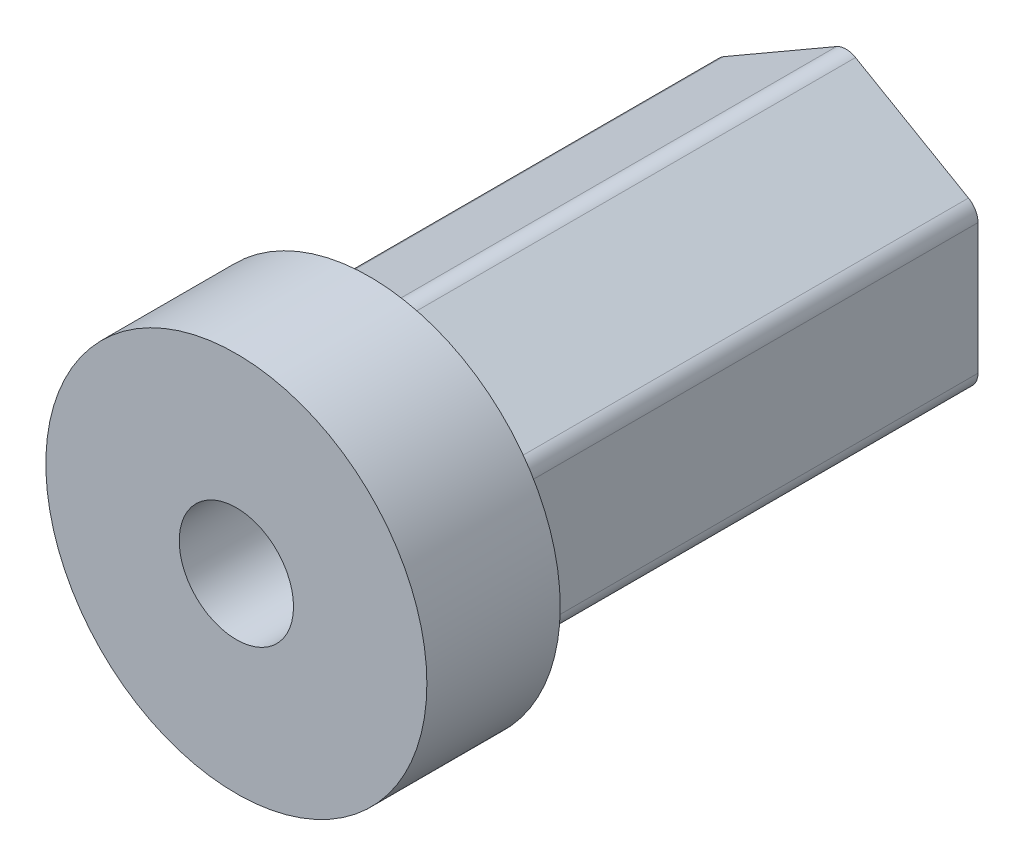
from build123d import *

# Parameters (mm, degrees)
CUT_EXTRUDE1_DEPTH = 25
FILLET1_R          = 1


with BuildPart() as part:
    # Sketch2 → Revolve1 (revolve)
    with BuildSketch(Plane(origin=(0, 0, 0), x_dir=(0, 0, -1), z_dir=(1, 0, 0))):
        Polygon((-7, 3), (25, 3), (25, 8), (0, 8), (0, 10), (-7, 10), align=None)
    revolve(axis=Axis((0, 0, 0), (0, 0, -1)))

    # Sketch3 → Cut-Extrude1 (cut)
    with BuildSketch(Plane(origin=(0, 0, -25), x_dir=(-1, 0, 0), z_dir=(0, 0, -1))):
        with BuildLine():
            ThreePointArc((0, 8), (-4, 6.92820323), (-6.92820323, 4))
            Line((-6.92820323, 4), (0, 8))
        make_face()
        with BuildLine():
            ThreePointArc((-6.92820323, 4), (-8, 0), (-6.92820323, -4))
            Line((-6.92820323, -4), (-6.92820323, 4))
        make_face()
        with BuildLine():
            ThreePointArc((-6.92820323, -4), (-4, -6.92820323), (0, -8))
            Line((0, -8), (-6.92820323, -4))
        make_face()
        with BuildLine():
            Line((6.92820323, -4), (0, -8))
            ThreePointArc((0, -8), (4, -6.92820323), (6.92820323, -4))
        make_face()
        with BuildLine():
            Line((6.92820323, 4), (6.92820323, -4))
            ThreePointArc((6.92820323, -4), (7.72740661, -2.070552361), (8, 0))
            ThreePointArc((8, 0), (7.72740661, 2.070552361), (6.92820323, 4))
        make_face()
        with BuildLine():
            Line((0, 8), (6.92820323, 4))
            ThreePointArc((6.92820323, 4), (4, 6.92820323), (0, 8))
        make_face()
    extrude(amount=-CUT_EXTRUDE1_DEPTH, mode=Mode.SUBTRACT)

    # Fillet1
    fillet1_edges = [part.edges().sort_by_distance(p)[0] for p in [
        (0, 8, -12.5),
        (6.92820323, 4, -12.5),
        (6.92820323, -4, -12.5),
        (0, -8, -12.5),
        (-6.92820323, -4, -12.5),
        (-6.92820323, 4, -12.5),
    ]]
    fillet(fillet1_edges, radius=FILLET1_R)


solid = part.part
